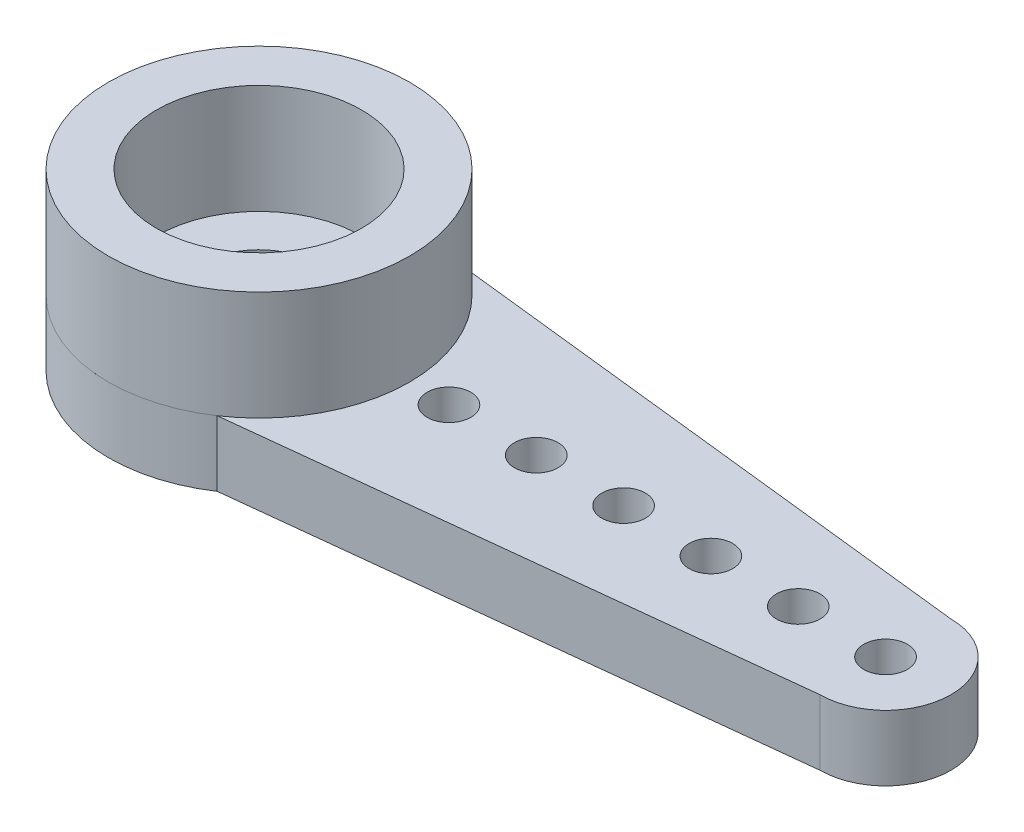
from build123d import *

# Parameters (mm, degrees)
SKETCH1_R           = 2.35
SKETCH1_R_2         = 0.5
BOSS_EXTRUDE1_DEPTH = 1.5
SKETCH2_R           = 2.35
SKETCH2_R_2         = 1.275
BOSS_EXTRUDE3_DEPTH = 0.5
SKETCH2_7_R         = 3.45
SKETCH2_7_R_2       = 2.35
BOSS_EXTRUDE5_DEPTH = 2.5


with BuildPart() as part:
    # Sketch1 → Boss-Extrude1 (new body)
    with BuildSketch(Plane(origin=(0, 0, 0), x_dir=(1, 0, 0), z_dir=(0, 1, 0))):
        with BuildLine():
            Line((14.35, 1.5), (1.879742768, 2.892933999))
            ThreePointArc((1.879742768, 2.892933999), (-3.449941889, -0.020024107), (1.913197247, -2.870919068))
            Line((1.913197247, -2.870919068), (14.35, -1.5))
            ThreePointArc((14.35, -1.5), (15.85, 0), (14.35, 1.5))
        make_face()
        Circle(SKETCH1_R, mode=Mode.SUBTRACT)
        with Locations((12.35, 0)):
            Circle(SKETCH1_R_2, mode=Mode.SUBTRACT)
        with Locations((14.35, 0)):
            Circle(SKETCH1_R_2, mode=Mode.SUBTRACT)
        with Locations((10.35, 0)):
            Circle(SKETCH1_R_2, mode=Mode.SUBTRACT)
        with Locations((8.35, 0)):
            Circle(SKETCH1_R_2, mode=Mode.SUBTRACT)
        with Locations((6.35, 0)):
            Circle(SKETCH1_R_2, mode=Mode.SUBTRACT)
        with Locations((4.35, 0)):
            Circle(SKETCH1_R_2, mode=Mode.SUBTRACT)
    extrude(amount=BOSS_EXTRUDE1_DEPTH)


with BuildPart() as body_2:
    # Sketch2 → Boss-Extrude3 (new body)
    with BuildSketch(Plane(origin=(0, 1.5, 0), x_dir=(1, 0, 0), z_dir=(0, 1, 0))):
        Circle(SKETCH2_R)
        Circle(SKETCH2_R_2, mode=Mode.SUBTRACT)
    extrude(amount=-BOSS_EXTRUDE3_DEPTH)


with BuildPart() as body_3:
    # Sketch2_7 → Boss-Extrude5 (new body)
    with BuildSketch(Plane(origin=(0, 1.5, 0), x_dir=(1, 0, 0), z_dir=(0, 1, 0))):
        Circle(SKETCH2_7_R)
        Circle(SKETCH2_7_R_2, mode=Mode.SUBTRACT)
    extrude(amount=BOSS_EXTRUDE5_DEPTH)


solid = Compound([part.part, body_2.part, body_3.part])
